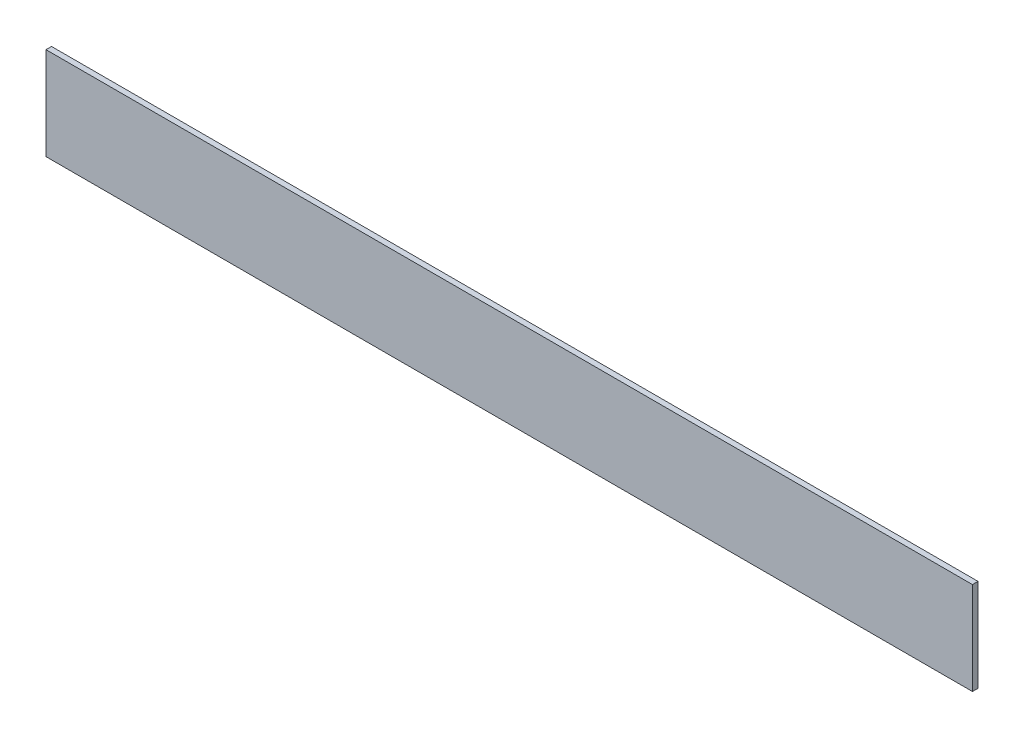
from build123d import *

# Parameters (mm, degrees)
ESQUISSE1_W        = 500
ESQUISSE1_H        = 50
BOSS_EXTRU_1_DEPTH = 3


with BuildPart() as part:
    # Esquisse1 → Boss.-Extru.1 (new body)
    with BuildSketch(Plane.XY):
        with Locations((510.84209689, -5.547081218)):
            Rectangle(ESQUISSE1_W, ESQUISSE1_H)
    extrude(amount=BOSS_EXTRU_1_DEPTH)


solid = part.part
